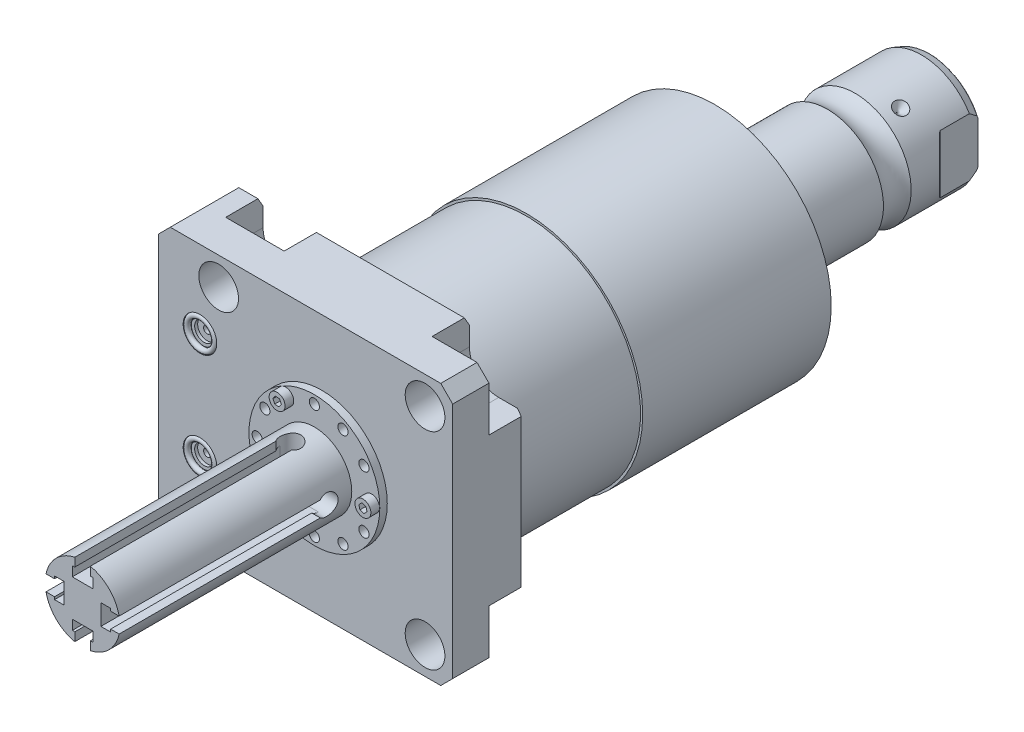
from build123d import *

# Parameters (mm, degrees)
SKETCH1_W                   = 99.9998
SKETCH1_H                   = 88.9
EXTRUDE1_DEPTH              = 25.019
SKETCH2_R                   = 6.7437
CUT_EXTRUDE1_DEPTH          = 27.5209
LPATTERN1_COUNT             = 2
LPATTERN1_PITCH             = 70.104
LPATTERN1_COUNT_DIR2        = 2
LPATTERN1_PITCH_DIR2        = 70.104
CUT_EXTRUDE2_DEPTH          = 12.7
SKETCH6_R                   = 5.7023
CUT_EXTRUDE3_DEPTH          = 1.4478
SKETCH7_R                   = 3.2512
CUT_EXTRUDE4_DEPTH          = 1.016
SKETCH8_R                   = 1.2446
CUT_EXTRUDE5_DEPTH          = 11.9888
SKETCH9_R                   = 0.9271
LPATTERN3_COUNT             = 2
LPATTERN3_PITCH             = 36.2204
CHAMFER1_SIZE               = 4.064
CHAMFER2_SIZE               = 3.0226
CHAMFER2_SIZE2              = 1.745098924
SKETCH14_R                  = 39.5224
EXTRUDE2_DEPTH              = 112.268
SKETCH15_OUTSIDE_W          = 140.4
SKETCH15_OUTSIDE_H          = 129.3
SKETCH15_OUTSIDE_R          = 38.7858
CUT_EXTRUDE9_DEPTH          = 44.45
CIRPATTERN1_COUNT           = 3
FILLET1_R                   = 0.635
CUT_EXTRUDE12_DEPTH         = 45.45
CUT_EXTRUDE12_DEPTH_BACK    = 45.45
SKETCH28_R                  = 1.7272
CUT_EXTRUDE13_DEPTH         = 2.54
SKETCH29_R                  = 2.7051
EXTRUDE3_DEPTH              = 2.9464
CUT_EXTRUDE14_DEPTH         = 2.032
CUT_EXTRUDE15_DEPTH         = 6.477
SKETCH32_W                  = 6.985
SKETCH32_H                  = 70.612
CUT_EXTRUDE16_DEPTH         = 3.302
CIRPATTERN2_COUNT           = 2
CIRPATTERN2_ANGLE           = 90
CIRPATTERN2_COPY_1_DEPTH    = 6.477
CIRPATTERN2_COPY_2_SKETCH_W = 6.985
CIRPATTERN2_COPY_2_SKETCH_H = 70.612
CIRPATTERN2_COPY_2_DEPTH    = 3.302


with BuildPart() as part:
    # Sketch1 → Extrude1 (new body)
    with BuildSketch(Plane.XY):
        with Locations((-5.5499, 0)):
            Rectangle(SKETCH1_W, SKETCH1_H)
    extrude(amount=EXTRUDE1_DEPTH)

    # Sketch2 → Cut-Extrude1 (cut)
    with BuildSketch(Plane(origin=(0, 0, 0), x_dir=(-1, 0, 0), z_dir=(0, 0, -1))):
        with Locations((-35.052, -35.052)):
            Circle(SKETCH2_R)
    cut_extrude1 = extrude(amount=-CUT_EXTRUDE1_DEPTH, mode=Mode.SUBTRACT)

    # LPattern1: Cut-Extrude1 2 × 2
    with Locations(*[(-j * LPATTERN1_PITCH_DIR2, i * LPATTERN1_PITCH, 0) for i in range(LPATTERN1_COUNT) for j in range(LPATTERN1_COUNT_DIR2) if (i, j) != (0, 0)]):
        add(cut_extrude1, mode=Mode.SUBTRACT)

    # Sketch3 → Cut-Extrude2 (cut)
    with BuildSketch(Plane(origin=(0, 0, 0), x_dir=(-1, 0, 0), z_dir=(0, 0, -1))):
        with BuildLine():
            Line((-35.052, -25.1206), (-44.45, -25.1206))
            Line((-44.45, -25.1206), (-44.45, -44.45))
            Line((-44.45, -44.45), (-25.1206, -44.45))
            Line((-25.1206, -44.45), (-25.1206, -35.052))
            ThreePointArc((-25.1206, -35.052), (-28.029439713, -28.029439713), (-35.052, -25.1206))
        make_face()
        with BuildLine():
            Line((-44.45, 25.1206), (-44.45, 44.45))
            Line((-44.45, 44.45), (-25.1206, 44.45))
            Line((-25.1206, 44.45), (-25.1206, 35.052))
            ThreePointArc((-25.1206, 35.052), (-28.029439713, 28.029439713), (-35.052, 25.1206))
            Line((-35.052, 25.1206), (-44.45, 25.1206))
        make_face()
        with BuildLine():
            Line((25.1206, 44.45), (25.1206, 35.052))
            ThreePointArc((25.1206, 35.052), (35.052, 25.1206), (44.9834, 35.052))
            Line((44.9834, 35.052), (44.9834, 44.45))
            Line((44.9834, 44.45), (25.1206, 44.45))
        make_face()
        with BuildLine():
            Line((44.9834, -44.45), (25.1206, -44.45))
            Line((25.1206, -44.45), (25.1206, -35.052))
            ThreePointArc((25.1206, -35.052), (35.052, -25.1206), (44.9834, -35.052))
            Line((44.9834, -35.052), (44.9834, -44.45))
        make_face()
    extrude(amount=-CUT_EXTRUDE2_DEPTH, mode=Mode.SUBTRACT)

    # S2D0007 → Cut-Revolve1 (revolve, cut)
    with BuildSketch(Plane(origin=(-55.5498, -13.0048, 12.0142), x_dir=(0, 1, 0), z_dir=(0, 0, 1)), mode=Mode.PRIVATE) as cut_revolve1_sk:
        Polygon((0, 0), (10.4775, 0), (10.4775, -0.254), (6.1849, -0.254), (5.642306865, -2.8067), (4.9784, -3.470606865), (4.9784, -14.224), (0, -14.224), align=None)
    revolve(cut_revolve1_sk.sketch.rotate(Axis((-40.6146, -13.0048, 12.0142), (-1, 0, 0)), 90), axis=Axis((-40.6146, -13.0048, 12.0142), (-1, 0, 0)), mode=Mode.SUBTRACT)  # turned: the seam where the file's is

    # Sketch5 → Cut-Revolve2 (revolve, cut)
    with BuildSketch(Plane(origin=(-55.5498, 13.0048, 12.0142), x_dir=(0, 1, 0), z_dir=(0, 0, 1)), mode=Mode.PRIVATE) as cut_revolve2_sk:
        Polygon((0, 0), (10.4775, 0), (10.4775, -0.254), (6.1849, -0.254), (5.642306865, -2.8067), (4.9784, -3.470606865), (4.9784, -14.224), (0, -14.224), align=None)
    revolve(cut_revolve2_sk.sketch.rotate(Axis((-40.6146, 13.0048, 12.0142), (-1, 0, 0)), 90), axis=Axis((-40.6146, 13.0048, 12.0142), (-1, 0, 0)), mode=Mode.SUBTRACT)  # turned: the seam where the file's is

    # Sketch6 → Cut-Extrude3 (cut)
    with BuildSketch(Plane.XY.offset(25.019)):
        with Locations((-41.402, -18.1102)):
            Circle(SKETCH6_R)
        with Locations((-41.402, 18.1102)):
            Circle(SKETCH6_R)
    extrude(amount=-CUT_EXTRUDE3_DEPTH, mode=Mode.SUBTRACT)

    # Sketch7 → Cut-Extrude4 (cut)
    with BuildSketch(Plane.XY.offset(23.5712)):
        with Locations((-41.402, 18.1102)):
            Circle(SKETCH7_R)
        with Locations((-41.402, -18.1102)):
            Circle(SKETCH7_R)
    extrude(amount=-CUT_EXTRUDE4_DEPTH, mode=Mode.SUBTRACT)

    # Sketch8 → Cut-Extrude5 (cut)
    with BuildSketch(Plane.XY.offset(22.5552)):
        with Locations((-41.402, 18.1102)):
            Circle(SKETCH8_R)
        with Locations((-41.402, -18.1102)):
            Circle(SKETCH8_R)
    extrude(amount=-CUT_EXTRUDE5_DEPTH, mode=Mode.SUBTRACT)

    # Chamfer1
    chamfer1_edges = [part.edges().sort_by_distance(p)[0] for p in [
        (-55.5498, 44.45, 12.5095),
        (44.45, 44.45, 18.8595),
        (44.45, -44.45, 18.8595),
        (-55.5498, -44.45, 12.5095),
    ]]
    chamfer(chamfer1_edges, length=CHAMFER1_SIZE)

    # Chamfer2
    chamfer2_edges = [part.edges().sort_by_distance(p)[0] for p in [
        (-48.2346, -44.45, 0),
        (44.45, 0, 0),
        (0, 44.45, 0),
        (-48.2346, 44.45, 0),
        (0, -44.45, 0),
    ]]
    chamfer2_side = [part.faces().sort_by_distance(p)[0] for p in [
        (-6.590443221, 0, 0),
    ]]
    chamfer(chamfer2_edges, length=CHAMFER2_SIZE, length2=CHAMFER2_SIZE2, reference=chamfer2_side[0])

    # Sketch14 → Extrude2 (add)
    with BuildSketch(Plane(origin=(0, 0, 0), x_dir=(-1, 0, 0), z_dir=(0, 0, -1))):
        Circle(SKETCH14_R)
    extrude(amount=EXTRUDE2_DEPTH)

    # Sketch15 outside → Cut-Extrude9 (cut)
    with BuildSketch(Plane(origin=(0, 0, 0), x_dir=(-1, 0, 0), z_dir=(0, 0, -1))):
        with Locations((5.55, 0)):
            Rectangle(SKETCH15_OUTSIDE_W, SKETCH15_OUTSIDE_H)
        Circle(SKETCH15_OUTSIDE_R, mode=Mode.SUBTRACT)
    extrude(amount=CUT_EXTRUDE9_DEPTH, mode=Mode.SUBTRACT)

    # Sketch16 → Cut-Revolve3 (revolve, cut)
    with BuildSketch(Plane(origin=(0, 0, 0), x_dir=(0, 0, 1), z_dir=(1, 0, 0)), mode=Mode.PRIVATE) as cut_revolve3_sk:
        Polygon((-112.268, 25.4), (-108.483914325, 39.5224), (-112.268, 39.5224), align=None)
    revolve(cut_revolve3_sk.sketch.rotate(Axis((0, 0, -96.582204284), (0, 0, 1)), 270), axis=Axis((0, 0, -96.582204284), (0, 0, 1)), mode=Mode.SUBTRACT)  # turned: the seam where the file's is

    # Sketch17 → Revolve3 (revolve)
    with BuildSketch(Plane(origin=(0, 0, 0), x_dir=(0, 0, 1), z_dir=(1, 0, 0)), mode=Mode.PRIVATE) as revolve3_sk:
        with BuildLine():
            Line((-112.268, 0), (-112.268, 19.05))
            Line((-112.268, 19.05), (-146.70230643, 19.05))
            ThreePointArc((-146.70230643, 19.05), (-151.4094, 17.5006), (-156.11649357, 19.05))
            Line((-156.11649357, 19.05), (-178.6636, 19.05))
            Line((-178.6636, 19.05), (-181.5846, 17.986842946))
            Line((-181.5846, 17.986842946), (-181.5846, 0))
            Line((-181.5846, 0), (-112.268, 0))
        make_face()
    revolve(revolve3_sk.sketch.rotate(Axis((0, 0, -180.9369), (0, 0, 1)), 270), axis=Axis((0, 0, -180.9369), (0, 0, 1)))  # turned: the seam where the file's is

    # Sketch22 → Cut-Revolve4 (revolve, cut)
    with BuildSketch(Plane(origin=(0, 0, 0), x_dir=(1, 0, 0), z_dir=(0, 1, 0)), mode=Mode.PRIVATE) as cut_revolve4_sk:
        Polygon((-19.05, 164.4904), (-16.637, 162.0774), (-19.05, 162.0774), align=None)
    cut_revolve4 = revolve(cut_revolve4_sk.sketch.rotate(Axis((-42.100308337, 0, -162.0774), (1, 0, 0)), 180), axis=Axis((-42.100308337, 0, -162.0774), (1, 0, 0)), mode=Mode.SUBTRACT)  # turned: the seam where the file's is

    # CirPattern1: Cut-Revolve4 ×3 about axis
    cirpattern1_axis = Axis((0, 0, -180.9369), (0, 0, -1))
    for i in range(1, CIRPATTERN1_COUNT):
        add(cut_revolve4.rotate(cirpattern1_axis, i * 360 / CIRPATTERN1_COUNT), mode=Mode.SUBTRACT)

    # Fillet1
    fillet1_edges = [part.edges().sort_by_distance(p)[0] for p in [
        (17.986842946, 0, -181.5846),
    ]]
    fillet(fillet1_edges, radius=FILLET1_R)

    # Sketch24 → Hole1 (revolve, cut)
    with BuildSketch(Plane(origin=(0, 0, -181.5846), x_dir=(0, 1, 0), z_dir=(1, 0, 0))):
        Polygon((0, 0), (0, 25.399999974), (6.9342, 21.23351227), (6.9342, 0), align=None)
    revolve(axis=Axis((0, 0, -185.828799587), (0, 0, 1)), mode=Mode.SUBTRACT)

    # Sketch26 → Cut-Extrude12 (cut, two sides)
    with BuildSketch(Plane(origin=(0, 0, 0), x_dir=(1, 0, 0), z_dir=(0, 1, 0))) as cut_extrude12_sk:
        with BuildLine():
            Line((-16.2814, 181.5846), (-16.2814, 168.8846))
            ThreePointArc((-16.2814, 168.8846), (-16.339403796, 168.592995225), (-16.504584633, 168.345784633))
            Line((-16.504584633, 168.345784633), (-19.05, 165.800369265))
            Line((-19.05, 165.800369265), (-19.05, 181.5846))
            Line((-19.05, 181.5846), (-16.2814, 181.5846))
        make_face()
        with BuildLine():
            Line((19.05, 181.5846), (16.2814, 181.5846))
            Line((16.2814, 181.5846), (16.2814, 168.8846))
            ThreePointArc((16.2814, 168.8846), (16.339403796, 168.592995225), (16.504584633, 168.345784633))
            Line((16.504584633, 168.345784633), (19.05, 165.800369265))
            Line((19.05, 165.800369265), (19.05, 181.5846))
        make_face()
    extrude(amount=CUT_EXTRUDE12_DEPTH, mode=Mode.SUBTRACT)
    extrude(cut_extrude12_sk.sketch, amount=-CUT_EXTRUDE12_DEPTH_BACK, mode=Mode.SUBTRACT)

    # Sketch27 → Revolve4 (revolve)
    with BuildSketch(Plane(origin=(0, 0, 0), x_dir=(1, 0, 0), z_dir=(0, 1, 0)), mode=Mode.PRIVATE) as revolve4_sk:
        Polygon((0, -25.019), (22.225, -25.019), (22.225, -27.559), (12.7, -27.559), (12.7, -106.299), (0, -106.299), align=None)
    revolve(revolve4_sk.sketch.rotate(Axis((0, 0, 1010.393251724), (0, 0, -1)), 180), axis=Axis((0, 0, 1010.393251724), (0, 0, -1)))  # turned: the seam where the file's is

    # Sketch28 → Cut-Extrude13 (cut)
    with BuildSketch(Plane.XY.offset(27.559)):
        with Locations((19.431, 0)):
            Circle(SKETCH28_R)
        with Locations((16.827739621, 9.7155)):
            Circle(SKETCH28_R)
        with Locations((9.7155, 16.827739621)):
            Circle(SKETCH28_R)
        with Locations((0, 19.431)):
            Circle(SKETCH28_R)
        with Locations(Location((-9.7155, 16.827739621, 0), (0, 0, 180))):  # turned: the seam where the file's is
            Circle(SKETCH28_R)
        with Locations(Location((-16.827739621, 9.7155, 0), (0, 0, 180))):  # turned: the seam where the file's is
            Circle(SKETCH28_R)
        with Locations(Location((-19.431, 0, 0), (0, 0, 180))):  # turned: the seam where the file's is
            Circle(SKETCH28_R)
        with Locations(Location((16.827739621, -9.7155, 0), (0, 0, 180))):  # turned: the seam where the file's is
            Circle(SKETCH28_R)
        with Locations(Location((9.7155, -16.827739621, 0), (0, 0, 180))):  # turned: the seam where the file's is
            Circle(SKETCH28_R)
        with Locations(Location((0, -19.431, 0), (0, 0, 180))):  # turned: the seam where the file's is
            Circle(SKETCH28_R)
        with Locations((-9.7155, -16.827739621)):
            Circle(SKETCH28_R)
        with Locations((-16.827739621, -9.7155)):
            Circle(SKETCH28_R)
    extrude(amount=-CUT_EXTRUDE13_DEPTH, mode=Mode.SUBTRACT)

    # Sketch29 → Extrude3 (add)
    with BuildSketch(Plane.XY.offset(27.559)):
        with Locations((19.431, 0)):
            Circle(SKETCH29_R)
        with Locations((-9.7155, 16.827739621)):
            Circle(SKETCH29_R)
        with Locations((-9.7155, -16.827739621)):
            Circle(SKETCH29_R)
    extrude(amount=EXTRUDE3_DEPTH)

    # Sketch30 → Cut-Extrude14 (cut)
    with BuildSketch(Plane.XY.offset(30.5054)):
        Polygon((19.802173147, -1.388381327), (20.818960073, -0.372745288), (20.447786925, 1.015636038), (19.059826853, 1.388381327), (18.043039927, 0.372745288), (18.414213075, -1.015636038), align=None)
        Polygon((-9.086136589, 15.535735786), (-8.281910151, 16.726782406), (-8.911273563, 18.018786241), (-10.344863411, 18.119743456), (-11.149089849, 16.928696836), (-10.519726437, 15.636693001), align=None)
        Polygon((-9.022139215, -18.086557731), (-8.278651145, -16.856680622), (-8.97201193, -15.597862512), (-10.408860785, -15.56892151), (-11.152348855, -16.798798619), (-10.45898807, -18.05761673), align=None)
    extrude(amount=-CUT_EXTRUDE14_DEPTH, mode=Mode.SUBTRACT)

    # Sketch31 → Cut-Extrude15 (cut)
    with BuildSketch(Plane(origin=(0, 12.7, 66.929), x_dir=(-1, 0, 0), z_dir=(0, 1, 0))):
        with BuildLine():
            Line((-2.6416, 39.37), (-2.6416, -28.957376248))
            ThreePointArc((-2.6416, -28.957376248), (0, -34.7345), (2.6416, -28.957376248))
            Line((2.6416, -28.957376248), (2.6416, 39.37))
            Line((2.6416, 39.37), (-2.6416, 39.37))
        make_face()
    cut_extrude15 = extrude(amount=-CUT_EXTRUDE15_DEPTH, mode=Mode.SUBTRACT)

    # Sketch32 → Cut-Extrude16 (cut)
    with BuildSketch(Plane(origin=(0, 6.223, 0), x_dir=(1, 0, 0), z_dir=(0, 1, 0))):
        with Locations((0, -70.993)):
            Rectangle(SKETCH32_W, SKETCH32_H)
    cut_extrude16 = extrude(amount=CUT_EXTRUDE16_DEPTH, mode=Mode.SUBTRACT)

    # Mirror1: Cut-Extrude15, Cut-Extrude16 across plane
    add(cut_extrude15.mirror(Plane.ZX), mode=Mode.SUBTRACT)
    add(cut_extrude16.mirror(Plane.ZX), mode=Mode.SUBTRACT)

    # CirPattern2: Cut-Extrude15, Cut-Extrude16 ×2 about axis
    cirpattern2_axis = Axis((0, 0, 0), (0, 0, 1))
    add([cut_extrude15.rotate(cirpattern2_axis, i * CIRPATTERN2_ANGLE / (CIRPATTERN2_COUNT - 1)) for i in range(1, CIRPATTERN2_COUNT)], mode=Mode.SUBTRACT)
    add([cut_extrude16.rotate(cirpattern2_axis, i * CIRPATTERN2_ANGLE / (CIRPATTERN2_COUNT - 1)) for i in range(1, CIRPATTERN2_COUNT)], mode=Mode.SUBTRACT)

    # CirPattern2 copy 1 sketch → CirPattern2 copy 1 (cut)
    with BuildSketch(Plane(origin=(12.7, 0, 66.929), x_dir=(0, -1, 0), z_dir=(1, 0, 0))):
        with BuildLine():
            Line((-2.6416, -39.37), (-2.6416, 28.957376248))
            ThreePointArc((-2.6416, 28.957376248), (0, 34.7345), (2.6416, 28.957376248))
            Line((2.6416, 28.957376248), (2.6416, -39.37))
            Line((2.6416, -39.37), (-2.6416, -39.37))
        make_face()
    extrude(amount=-CIRPATTERN2_COPY_1_DEPTH, mode=Mode.SUBTRACT)

    # CirPattern2 copy 2 sketch → CirPattern2 copy 2 (cut)
    with BuildSketch(Plane.YZ.offset(6.223)):
        with Locations((0, 70.993)):
            Rectangle(CIRPATTERN2_COPY_2_SKETCH_W, CIRPATTERN2_COPY_2_SKETCH_H)
    extrude(amount=CIRPATTERN2_COPY_2_DEPTH, mode=Mode.SUBTRACT)


with BuildPart() as body_2:
    # Sketch9 → Revolve1 (revolve)
    with BuildSketch(Plane(origin=(-41.656, 18.1102, 23.5712), x_dir=(1, 0, 0), z_dir=(0, 1, 0))):
        with Locations((5.0292, -0.9271)):
            Circle(SKETCH9_R)
    revolve(axis=Axis((-41.402, 18.1102, 25.51811), (0, 0, -1)))


with BuildPart() as lpattern3_1:
    # LPattern3: pattern copy
    add(body_2.part.moved(Location(Vector(0, -1, 0) * (1 * LPATTERN3_PITCH))))


solid = Compound([part.part, body_2.part, lpattern3_1.part])
